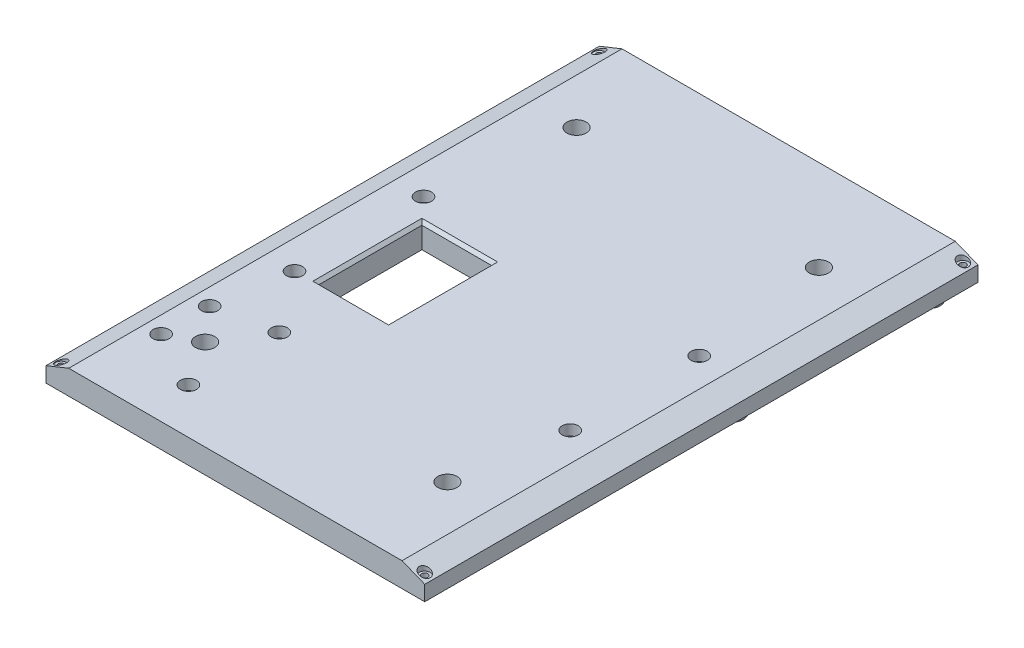
from build123d import *

# Parameters (mm, degrees)
BOSS_EXTRUDE1_DEPTH = 182.6
SKETCH2_R           = 2.5
SKETCH2_R_2         = 0.85
BOSS_EXTRUDE2_DEPTH = 3
SKETCH3_R           = 3.175
CUT_EXTRUDE1_DEPTH  = 15
SKETCH4_R           = 2.6
SKETCH4_R_2         = 1.55
BOSS_EXTRUDE3_DEPTH = 6
SKETCH7_R           = 1.6
CUT_EXTRUDE3_DEPTH  = 10
SKETCH8_R           = 1.6
CUT_EXTRUDE4_DEPTH  = 10
SKETCH6_R           = 0.85
CUT_EXTRUDE2_DEPTH  = 7
SKETCH9_R           = 3.5
SKETCH9_R_2         = 1.95
BOSS_EXTRUDE4_DEPTH = 5
SKETCH10_R          = 1.6
CUT_EXTRUDE5_DEPTH  = 10
SKETCH11_W          = 23
SKETCH11_H          = 34
CUT_EXTRUDE6_DEPTH  = 10
CHAMFER1_SIZE       = 1
SKETCH12_R          = 2.65
CUT_EXTRUDE7_DEPTH  = 3.5
SKETCH13_R          = 1.05
CUT_EXTRUDE8_DEPTH  = 8
SKETCH15_R          = 1.8
CUT_EXTRUDE9_DEPTH  = 3


with BuildPart() as part:
    # Sketch1 → Boss-Extrude1 (new body)
    with BuildSketch(Plane.XY):
        Polygon((0, 5), (7.5, 8), (117.5, 8), (125, 5), (125, 0), (0, 0), align=None)
    extrude(amount=BOSS_EXTRUDE1_DEPTH)

    # Sketch2 → Boss-Extrude2 (add)
    with BuildSketch(Plane.XZ):
        with Locations((40, 173.1)):
            Circle(SKETCH2_R)
        with Locations((40, 173.1)):
            Circle(SKETCH2_R_2, mode=Mode.SUBTRACT)
        with Locations((98, 173.1)):
            Circle(SKETCH2_R)
        with Locations((98, 173.1)):
            Circle(SKETCH2_R_2, mode=Mode.SUBTRACT)
        with Locations((98, 124.1)):
            Circle(SKETCH2_R)
        with Locations((98, 124.1)):
            Circle(SKETCH2_R_2, mode=Mode.SUBTRACT)
        with Locations((40, 124.1)):
            Circle(SKETCH2_R)
        with Locations((40, 124.1)):
            Circle(SKETCH2_R_2, mode=Mode.SUBTRACT)
    extrude(amount=BOSS_EXTRUDE2_DEPTH)

    # Sketch3 → Cut-Extrude1 (cut)
    with BuildSketch(Plane(origin=(0, 8, 0), x_dir=(1, 0, 0), z_dir=(0, 1, 0))):
        with Locations((22.5, -152.6)):
            Circle(SKETCH3_R)
        with Locations((102.5, -152.6)):
            Circle(SKETCH3_R)
        with Locations((102.5, -30)):
            Circle(SKETCH3_R)
        with Locations((22.5, -30)):
            Circle(SKETCH3_R)
    extrude(amount=-CUT_EXTRUDE1_DEPTH, mode=Mode.SUBTRACT)

    # Sketch4 → Boss-Extrude3 (add)
    with BuildSketch(Plane.XZ):
        with Locations((56.15, 81.14)):
            Circle(SKETCH4_R)
        with Locations((56.15, 81.14)):
            Circle(SKETCH4_R_2, mode=Mode.SUBTRACT)
        with Locations((68.85, 81.14)):
            Circle(SKETCH4_R)
        with Locations((68.85, 81.14)):
            Circle(SKETCH4_R_2, mode=Mode.SUBTRACT)
        with Locations((68.85, 101.46)):
            Circle(SKETCH4_R)
        with Locations((68.85, 101.46)):
            Circle(SKETCH4_R_2, mode=Mode.SUBTRACT)
        with Locations((56.15, 101.46)):
            Circle(SKETCH4_R)
        with Locations((56.15, 101.46)):
            Circle(SKETCH4_R_2, mode=Mode.SUBTRACT)
    extrude(amount=BOSS_EXTRUDE3_DEPTH)

    # Sketch7 → Cut-Extrude3 (cut)
    with BuildSketch(Plane(origin=(0, 8, 0), x_dir=(1, 0, 0), z_dir=(0, 1, 0))):
        with Locations((17, -75.01)):
            Circle(SKETCH7_R)
        with Locations((17, -117.585)):
            Circle(SKETCH7_R)
        with Locations((108, -75.01)):
            Circle(SKETCH7_R)
        with Locations((108, -117.59)):
            Circle(SKETCH7_R)
    extrude(amount=-CUT_EXTRUDE3_DEPTH, mode=Mode.SUBTRACT)

    # Sketch8 → Cut-Extrude4 (cut)
    with BuildSketch(Plane(origin=(0, 8, 0), x_dir=(1, 0, 0), z_dir=(0, 1, 0))):
        with Locations((13, -141.6)):
            Circle(SKETCH8_R)
        with Locations((13, -157.6)):
            Circle(SKETCH8_R)
    extrude(amount=-CUT_EXTRUDE4_DEPTH, mode=Mode.SUBTRACT)

    # Sketch6 → Cut-Extrude2 (cut)
    with BuildSketch(Plane.XZ):
        with Locations((22.407582627, 118.246238122)):
            Circle(SKETCH6_R)
        with Locations((48.407582627, 118.246238122)):
            Circle(SKETCH6_R)
        with Locations((48.407582627, 71.246238122)):
            Circle(SKETCH6_R)
        with Locations((22.407582627, 71.246238122)):
            Circle(SKETCH6_R)
    extrude(amount=-CUT_EXTRUDE2_DEPTH, mode=Mode.SUBTRACT)

    # Sketch9 → Boss-Extrude4 (add)
    with BuildSketch(Plane.XZ):
        with Locations((117, 73)):
            Circle(SKETCH9_R)
        with Locations((117, 73)):
            Circle(SKETCH9_R_2, mode=Mode.SUBTRACT)
        with Locations((117, 8)):
            Circle(SKETCH9_R)
        with Locations((117, 8)):
            Circle(SKETCH9_R_2, mode=Mode.SUBTRACT)
        with Locations((34, 8)):
            Circle(SKETCH9_R)
        with Locations((34, 8)):
            Circle(SKETCH9_R_2, mode=Mode.SUBTRACT)
        with Locations((34, 73)):
            Circle(SKETCH9_R)
        with Locations((34, 73)):
            Circle(SKETCH9_R_2, mode=Mode.SUBTRACT)
    extrude(amount=BOSS_EXTRUDE4_DEPTH)

    # Sketch10 → Cut-Extrude5 (cut)
    with BuildSketch(Plane(origin=(0, 8, 0), x_dir=(1, 0, 0), z_dir=(0, 1, 0))):
        with Locations((32, -137.6)):
            Circle(SKETCH10_R)
        with Locations((32, -167.6)):
            Circle(SKETCH10_R)
    extrude(amount=-CUT_EXTRUDE5_DEPTH, mode=Mode.SUBTRACT)

    # Sketch11 → Cut-Extrude6 (cut)
    with BuildSketch(Plane.XZ):
        with Locations((35.407582627, 99.446238122)):
            Rectangle(SKETCH11_W, SKETCH11_H)
    extrude(amount=-CUT_EXTRUDE6_DEPTH, mode=Mode.SUBTRACT)

    # Chamfer1
    chamfer1_edges = [part.edges().sort_by_distance(p)[0] for p in [
        (35.407582627, 8, 116.446238122),
        (23.907582627, 8, 99.446238122),
        (35.407582627, 8, 82.446238122),
        (46.907582627, 8, 99.446238122),
    ]]
    chamfer(chamfer1_edges, length=CHAMFER1_SIZE)

    # Sketch12 → Cut-Extrude7 (cut)
    with BuildSketch(Plane(origin=(0, 8, 0), x_dir=(1, 0, 0), z_dir=(0, 1, 0))):
        with Locations((17, -75.01)):
            Circle(SKETCH12_R)
        with Locations((108, -75.01)):
            Circle(SKETCH12_R)
        with Locations((108, -117.59)):
            Circle(SKETCH12_R)
        with Locations((32, -137.6)):
            Circle(SKETCH12_R)
        with Locations((32, -167.6)):
            Circle(SKETCH12_R)
        with Locations((13, -157.6)):
            Circle(SKETCH12_R)
        with Locations((13, -141.6)):
            Circle(SKETCH12_R)
        with Locations((17, -117.585)):
            Circle(SKETCH12_R)
    extrude(amount=-CUT_EXTRUDE7_DEPTH, mode=Mode.SUBTRACT)

    # Sketch13 → Cut-Extrude8 (cut)
    with BuildSketch(Plane(origin=(0, 8, 0), x_dir=(1, 0, 0), z_dir=(0, 1, 0))):
        with Locations((2.5, -180.1)):
            Circle(SKETCH13_R)
        with Locations((122.5, -180.1)):
            Circle(SKETCH13_R)
        with Locations((122.5, -2.5)):
            Circle(SKETCH13_R)
        with Locations((2.5, -2.5)):
            Circle(SKETCH13_R)
    extrude(amount=-CUT_EXTRUDE8_DEPTH, mode=Mode.SUBTRACT)

    # Sketch15 → Cut-Extrude9 (cut)
    with BuildSketch(Plane(origin=(0, 8, 0), x_dir=(1, 0, 0), z_dir=(0, 1, 0))):
        with Locations((2.5, -180.1)):
            Circle(SKETCH15_R)
        with Locations((2.5, -2.5)):
            Circle(SKETCH15_R)
        with Locations((122.5, -2.5)):
            Circle(SKETCH15_R)
        with Locations((122.5, -180.1)):
            Circle(SKETCH15_R)
    extrude(amount=-CUT_EXTRUDE9_DEPTH, mode=Mode.SUBTRACT)


solid = part.part
